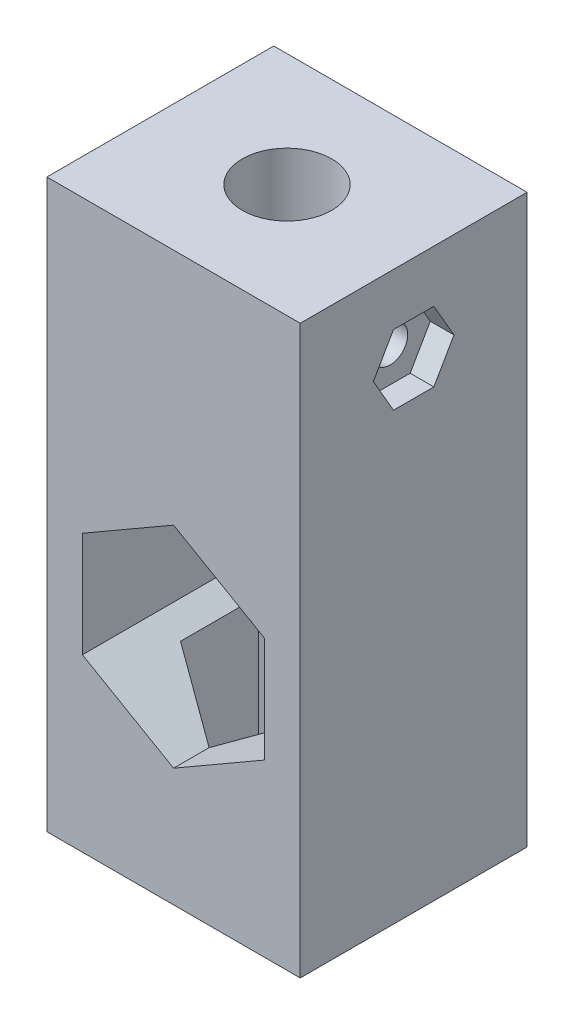
from build123d import *

# Parameters (mm, degrees)
ESQUISSE1_W                  = 21.4
ESQUISSE1_H                  = 19.163586138
BOSS_EXTRU_1_DEPTH           = 47.9
ENL_V_MAT_EXTRU_1_DEPTH      = 32.9
ENL_V_MAT_EXTRU_2_REACH      = 49.9
ESQUISSE3_R                  = 3.775
ENL_V_MAT_EXTRU_3_DEPTH      = 1
ENL_V_MAT_EXTRU_3_DEPTH_BACK = 20.163586138
ESQUISSE5_R                  = 1.5
ENL_V_MAT_EXTRU_4_DEPTH      = 16
ENL_V_MAT_EXTRU_5_DEPTH      = 2


with BuildPart() as part:
    # Esquisse1 → Boss.-Extru.1 (new body)
    with BuildSketch(Plane(origin=(0, 0, 0), x_dir=(1, 0, 0), z_dir=(0, 1, 0))):
        Rectangle(ESQUISSE1_W, ESQUISSE1_H)
    extrude(amount=BOSS_EXTRU_1_DEPTH)

    # Esquisse2 → Enlèv. mat.-Extru.1 (cut)
    with BuildSketch(Plane(origin=(0, 0, 0), x_dir=(-1, 0, 0), z_dir=(0, -1, 0))):
        Polygon((5.7, -3.290896534), (0, -6.581793069), (-5.7, -3.290896534), (-5.7, 3.290896534), (0, 6.581793069), (5.7, 3.290896534), align=None)
    extrude(amount=-ENL_V_MAT_EXTRU_1_DEPTH, mode=Mode.SUBTRACT)

    # Esquisse3 → Enlèv. mat.-Extru.2 (cut, up to next)
    with BuildSketch(Plane(origin=(0, 47.9, 0), x_dir=(1, 0, 0), z_dir=(0, 1, 0)), mode=Mode.PRIVATE) as enl_v_mat_extru_2_sk1:
        with Locations(Location((0, 0, 0), (0, 0, 270))):  # turned: the seam where the file's is
            Circle(ESQUISSE3_R)
    enl_v_mat_extru_2_tool1 = extrude(enl_v_mat_extru_2_sk1.sketch, amount=-ENL_V_MAT_EXTRU_2_REACH, mode=Mode.PRIVATE) & part.part
    add(enl_v_mat_extru_2_tool1.solids().sort_by_distance((0, 47.9, 0))[0], mode=Mode.SUBTRACT)

    # Esquisse4 → Enlèv. mat.-Extru.3 (cut, two sides)
    with BuildSketch(Plane.XY.offset(9.581793069)) as enl_v_mat_extru_3_sk:
        Polygon((0, 27.782388291), (-7.7, 23.336791218), (-7.7, 14.445597073), (0, 10), (7.7, 14.445597073), (7.7, 23.336791218), align=None)
    extrude(amount=ENL_V_MAT_EXTRU_3_DEPTH, mode=Mode.SUBTRACT)
    extrude(enl_v_mat_extru_3_sk.sketch, amount=-ENL_V_MAT_EXTRU_3_DEPTH_BACK, mode=Mode.SUBTRACT)

    # Esquisse5 → Enlèv. mat.-Extru.4 (cut)
    with BuildSketch(Plane(origin=(10.7, 0, 0), x_dir=(0, 0, -1), z_dir=(1, 0, 0))):
        with Locations((0, 40.55)):
            Circle(ESQUISSE5_R)
    extrude(amount=-ENL_V_MAT_EXTRU_4_DEPTH, mode=Mode.SUBTRACT)

    # Esquisse6 → Enlèv. mat.-Extru.5 (cut)
    with BuildSketch(Plane(origin=(10.7, 0, 0), x_dir=(0, 0, -1), z_dir=(1, 0, 0))):
        Polygon((1.703183294, 43.5), (-1.703183294, 43.5), (-3.406366588, 40.55), (-1.703183294, 37.6), (1.703183294, 37.6), (3.406366588, 40.55), align=None)
    extrude(amount=-ENL_V_MAT_EXTRU_5_DEPTH, mode=Mode.SUBTRACT)


solid = part.part
